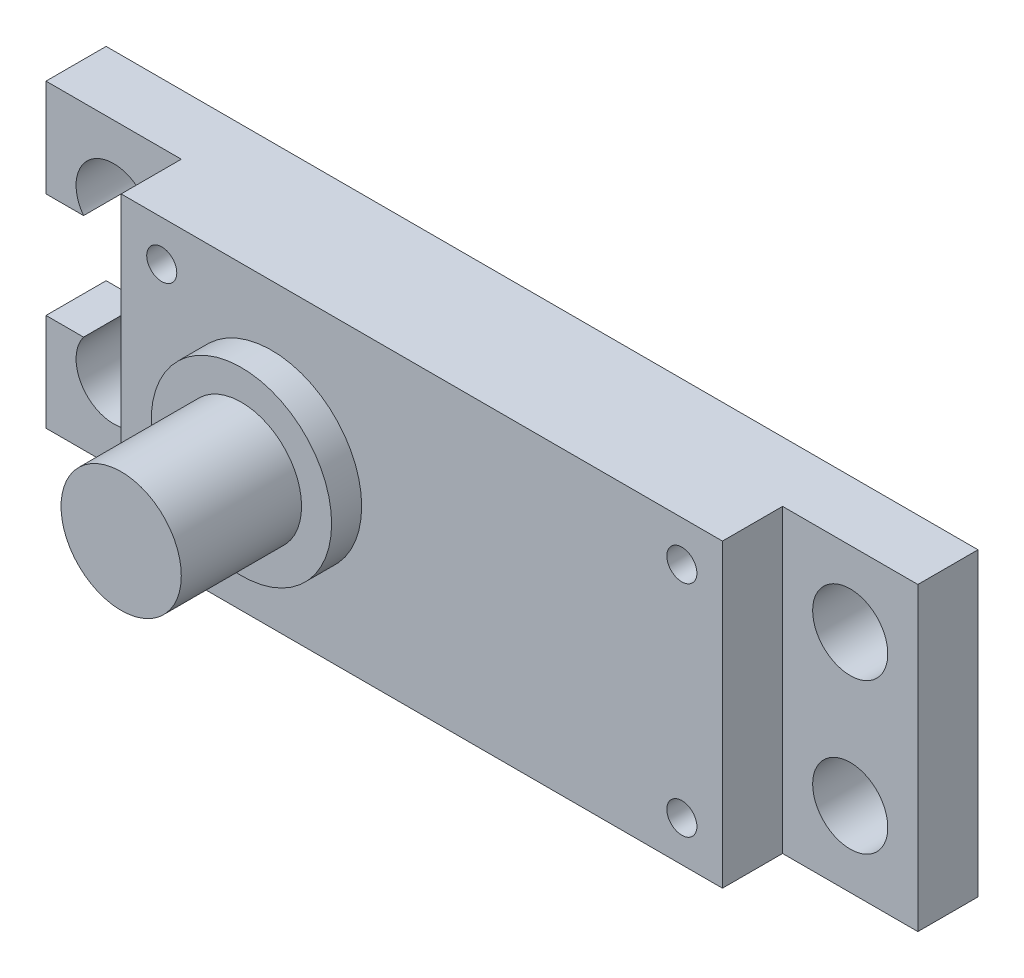
from build123d import *

# Parameters (mm, degrees)
ESQUISSE1_W             = 58
ESQUISSE1_H             = 20
EXTRUSION1_DEPTH        = 8
ESQUISSE2_W             = 37.4
ESQUISSE2_H             = 17.4
ENL_V_MAT_EXTRU_1_DEPTH = 6
ESQUISSE3_W             = 9
ESQUISSE3_H             = 4
ENL_V_MAT_EXTRU_2_DEPTH = 21
ESQUISSE4_R             = 2.5
ESQUISSE4_R_2           = 1
ENL_V_MAT_EXTRU_3_DEPTH = 9
ESQUISSE5_R             = 4
EXTRUSION2_DEPTH        = 10
ESQUISSE6_W             = 10.3
ESQUISSE6_H             = 7
ENL_V_MAT_EXTRU_4_DEPTH = 4
ESQUISSE10_W            = 37.4
ESQUISSE10_H            = 0.5
EXTRUSION8_DEPTH        = 20
ESQUISSE8_W             = 3
ESQUISSE8_H             = 15.4
EXTRUSION7_DEPTH        = 6.5
EXTRUSION7_TAPER        = 9
ESQUISSE11_R            = 6
EXTRUSION9_DEPTH        = 2


with BuildPart() as part:
    # Esquisse1 → Extrusion1 (new body)
    with BuildSketch(Plane.XY):
        with Locations((29, 10)):
            Rectangle(ESQUISSE1_W, ESQUISSE1_H)
    extrude(amount=EXTRUSION1_DEPTH)

    # Esquisse2 → Enlèv. mat.-Extru.1 (cut)
    with BuildSketch(Plane(origin=(0, 0, 0), x_dir=(-1, 0, 0), z_dir=(0, 0, -1))):
        with Locations((-29, 10)):
            Rectangle(ESQUISSE2_W, ESQUISSE2_H)
    extrude(amount=-ENL_V_MAT_EXTRU_1_DEPTH, mode=Mode.SUBTRACT)

    # Esquisse3 → Enlèv. mat.-Extru.2 (cut, through all)
    with BuildSketch(Plane(origin=(0, 20, 0), x_dir=(1, 0, 0), z_dir=(0, 1, 0))):
        with Locations((4.5, -6)):
            Rectangle(ESQUISSE3_W, ESQUISSE3_H)
        with Locations((53.5, -6)):
            Rectangle(ESQUISSE3_W, ESQUISSE3_H)
    extrude(amount=-ENL_V_MAT_EXTRU_2_DEPTH, mode=Mode.SUBTRACT)

    # Esquisse4 → Enlèv. mat.-Extru.3 (cut, through all)
    with BuildSketch(Plane(origin=(0, 0, 0), x_dir=(-1, 0, 0), z_dir=(0, 0, -1))):
        with Locations((-53.5, 15)):
            Circle(ESQUISSE4_R)
        with Locations((-46.3, 17.3)):
            Circle(ESQUISSE4_R_2)
        with Locations((-46.3, 2.7)):
            Circle(ESQUISSE4_R_2)
        with Locations((-53.5, 5)):
            Circle(ESQUISSE4_R)
        with Locations((-4.5, 5)):
            Circle(ESQUISSE4_R)
        with Locations((-11.7, 2.7)):
            Circle(ESQUISSE4_R_2)
        with Locations((-11.7, 17.3)):
            Circle(ESQUISSE4_R_2)
        with Locations((-4.5, 15)):
            Circle(ESQUISSE4_R)
    extrude(amount=-ENL_V_MAT_EXTRU_3_DEPTH, mode=Mode.SUBTRACT)

    # Esquisse5 → Extrusion2 (add)
    with BuildSketch(Plane.XY.offset(8)):
        with Locations((19, 10)):
            Circle(ESQUISSE5_R)
    extrude(amount=EXTRUSION2_DEPTH)

    # Esquisse6 → Enlèv. mat.-Extru.4 (cut)
    with BuildSketch(Plane(origin=(0, 0, 0), x_dir=(-1, 0, 0), z_dir=(0, 0, -1))):
        with Locations((-5.15, 10)):
            Rectangle(ESQUISSE6_W, ESQUISSE6_H)
    extrude(amount=-ENL_V_MAT_EXTRU_4_DEPTH, mode=Mode.SUBTRACT)

    # Esquisse10 → Extrusion8 (add)
    with BuildSketch(Plane(origin=(0, 20, 0), x_dir=(1, 0, 0), z_dir=(0, 1, 0))):
        with Locations((29, -6.25)):
            Rectangle(ESQUISSE10_W, ESQUISSE10_H)
    extrude(amount=-EXTRUSION8_DEPTH)

    # Esquisse8 → Extrusion7 (add)
    with BuildSketch(Plane(origin=(0, 0, 0), x_dir=(-1, 0, 0), z_dir=(0, 0, -1))):
        with Locations((-23.806848388, 10)):
            Rectangle(ESQUISSE8_W, ESQUISSE8_H)
        with Locations((-45.489222367, 10)):
            Rectangle(ESQUISSE8_W, ESQUISSE8_H)
        with Locations((-40.088484526, 10)):
            Rectangle(ESQUISSE8_W, ESQUISSE8_H)
        with Locations((-34.193151612, 10)):
            Rectangle(ESQUISSE8_W, ESQUISSE8_H)
        with Locations((-29, 10)):
            Rectangle(ESQUISSE8_W, ESQUISSE8_H)
        with Locations((-17.911515474, 10)):
            Rectangle(ESQUISSE8_W, ESQUISSE8_H)
        with Locations((-12.510777633, 10)):
            Rectangle(ESQUISSE8_W, ESQUISSE8_H)
    extrude(amount=-EXTRUSION7_DEPTH, taper=EXTRUSION7_TAPER)

    # Esquisse11 → Extrusion9 (add)
    with BuildSketch(Plane.XY.offset(8)):
        with Locations((19, 10)):
            Circle(ESQUISSE11_R)
    extrude(amount=EXTRUSION9_DEPTH)


solid = part.part
